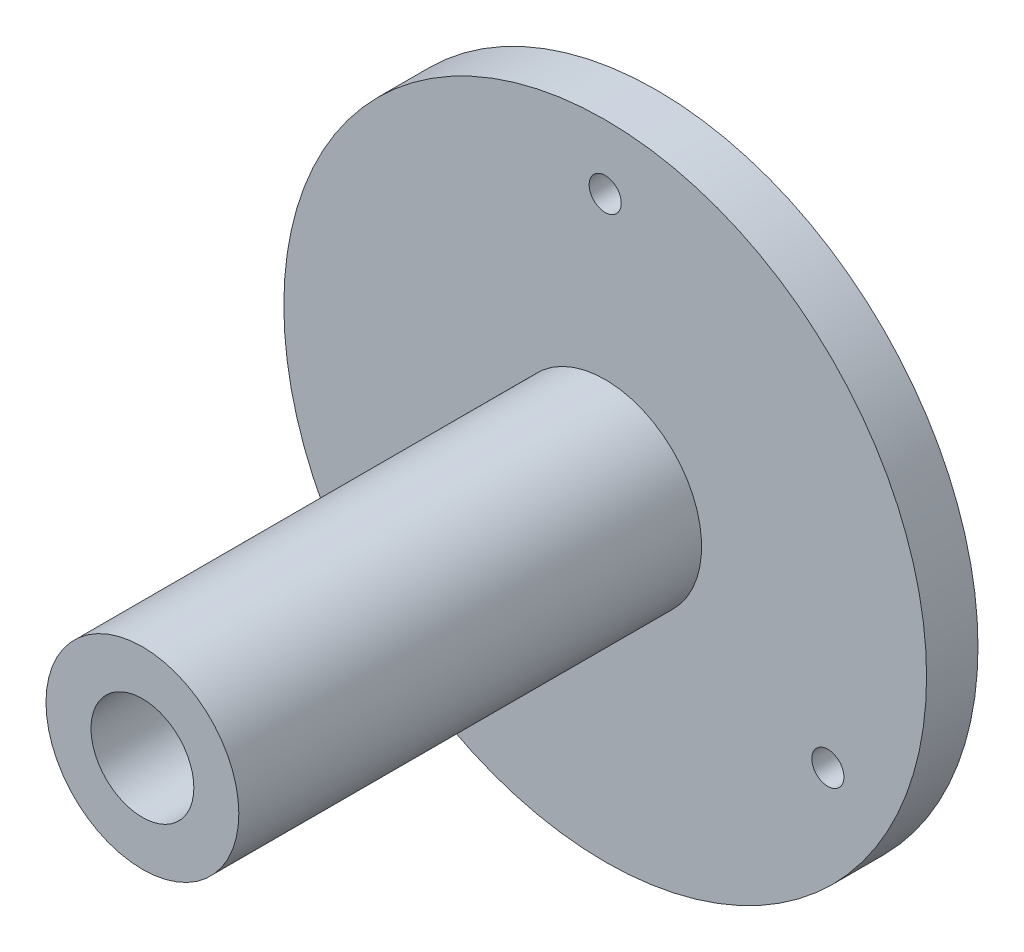
from build123d import *

# Parameters (mm, degrees)
SKETCH1_R           = 15
SKETCH1_R_2         = 8
BOSS_EXTRUDE1_DEPTH = 80
SKETCH2_R           = 50
SKETCH2_R_2         = 12.5
BOSS_EXTRUDE2_DEPTH = 8
SKETCH3_R           = 2.5
CUT_EXTRUDE1_DEPTH  = 8
CIRPATTERN1_COUNT   = 3


with BuildPart() as part:
    # Sketch1 → Boss-Extrude1 (new body)
    with BuildSketch(Plane.XY.offset(10)):
        Circle(SKETCH1_R)
        Circle(SKETCH1_R_2, mode=Mode.SUBTRACT)
    extrude(amount=BOSS_EXTRUDE1_DEPTH)

    # Sketch2 → Boss-Extrude2 (add)
    with BuildSketch(Plane(origin=(0, 0, 10), x_dir=(-1, 0, 0), z_dir=(0, 0, -1))):
        Circle(SKETCH2_R)
        Circle(SKETCH2_R_2, mode=Mode.SUBTRACT)
    extrude(amount=-BOSS_EXTRUDE2_DEPTH)

    # Sketch3 → Cut-Extrude1 (cut)
    with BuildSketch(Plane.XY.offset(18)):
        with Locations((0, 40)):
            Circle(SKETCH3_R)
    cut_extrude1 = extrude(amount=-CUT_EXTRUDE1_DEPTH, mode=Mode.SUBTRACT)

    # CirPattern1: Cut-Extrude1 ×3 about axis
    cirpattern1_axis = Axis((0, 0, 0), (0, 0, 1))
    for i in range(1, CIRPATTERN1_COUNT):
        add(cut_extrude1.rotate(cirpattern1_axis, i * 360 / CIRPATTERN1_COUNT), mode=Mode.SUBTRACT)


solid = part.part
